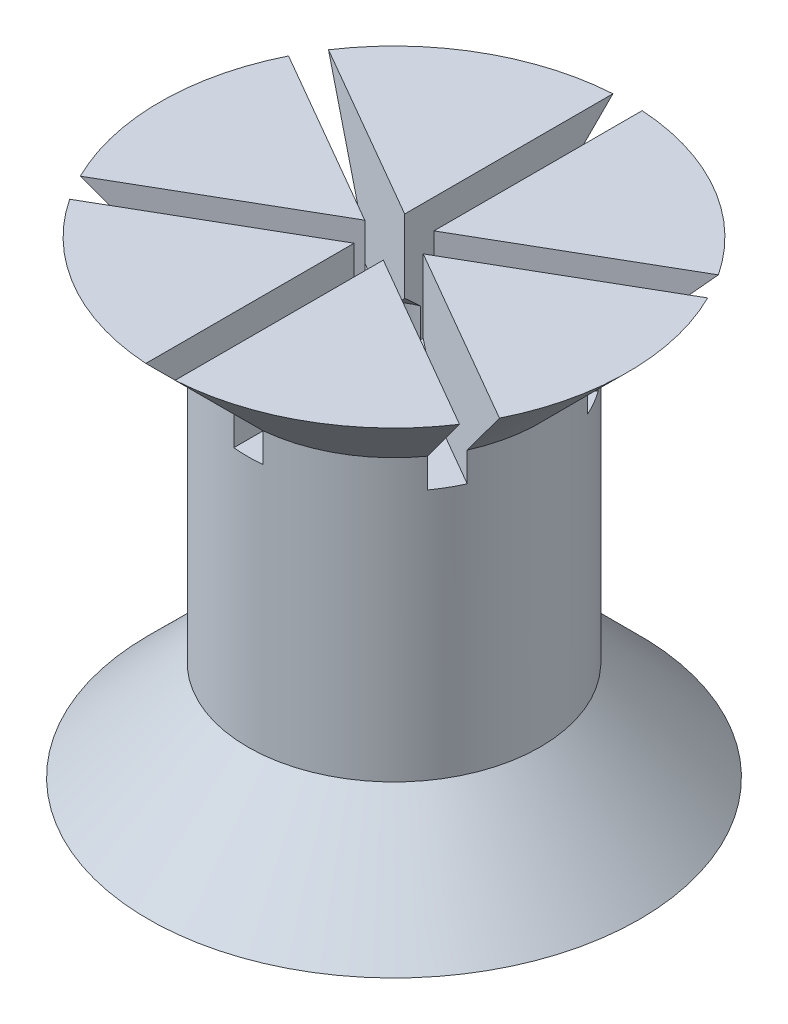
from build123d import *

# Parameters (mm, degrees)
SKETCH_2_R               = 10
EXTRUDE_1_DEPTH          = 3.4
SKETCH_5_W               = 5
SKETCH_5_H               = 8.6
CUT_EXTRUDE_1_DEPTH      = 0.5
PATTERN_CIRCULAR_1_COUNT = 6


with BuildPart() as part:
    # 草图2 → 凸台-拉伸1 (new body)
    with BuildSketch(Plane(origin=(0, -16, 0), x_dir=(-1, 0, 0), z_dir=(0, -1, 0))):
        Circle(SKETCH_2_R)
        Polygon((0, 3.0022214), (-2.6, 1.5011107), (-2.6, -1.5011107), (0, -3.0022214), (2.6, -1.5011107), (2.6, 1.5011107), align=None, mode=Mode.SUBTRACT)
    extrude(amount=-EXTRUDE_1_DEPTH)

    # 草图5 → 旋转1 (revolve)
    with BuildSketch(Plane.XY):
        with Locations((-2.5, -8.3)):
            Rectangle(SKETCH_5_W, SKETCH_5_H)
    revolve(axis=Axis((0, 22.928075319, 0), (0, -1, 0)))

    # 草图6 → 切除-旋转1 (revolve, cut)
    with BuildSketch(Plane.XY):
        Polygon((-5, -12.6), (-10, -17.6), (-10, -12.6), align=None)
    revolve(axis=Axis((0, 0, 0), (0, -1, 0)), mode=Mode.SUBTRACT)

    # 草图7 → 旋转2 (revolve)
    with BuildSketch(Plane.XY):
        Polygon((-5, -4), (0, -4), (0, 0), (-8, 0), (-5, -3), align=None)
    revolve(axis=Axis((0, 2.901504441, 0), (0, -1, 0)))

    # 草图8 → 切除-拉伸1 (cut, symmetric)
    with BuildSketch(Plane(origin=(0, 0, 0), x_dir=(0, 0, -1), z_dir=(1, 0, 0))):
        Polygon((-5, -3), (-8, 0), (0, 0), (0, -4), (-5, -4), align=None)
    cut_extrude_1 = extrude(amount=CUT_EXTRUDE_1_DEPTH, both=True, mode=Mode.SUBTRACT)

    # 阵列(圆周)1: 切除-拉伸1 ×6 about axis
    pattern_circular_1_axis = Axis((0, 0, 0), (0, 1, 0))
    for i in range(1, PATTERN_CIRCULAR_1_COUNT):
        add(cut_extrude_1.rotate(pattern_circular_1_axis, i * 360 / PATTERN_CIRCULAR_1_COUNT), mode=Mode.SUBTRACT)

    # 草图9 → 切除-旋转3 (revolve, cut)
    with BuildSketch(Plane.XY):
        Polygon((0, -4), (-1.5, -4), (-1.5, -3), (0, -1.5), align=None)
    revolve(axis=Axis((0, 4.48946261, 0), (0, -1, 0)), mode=Mode.SUBTRACT)


solid = part.part
